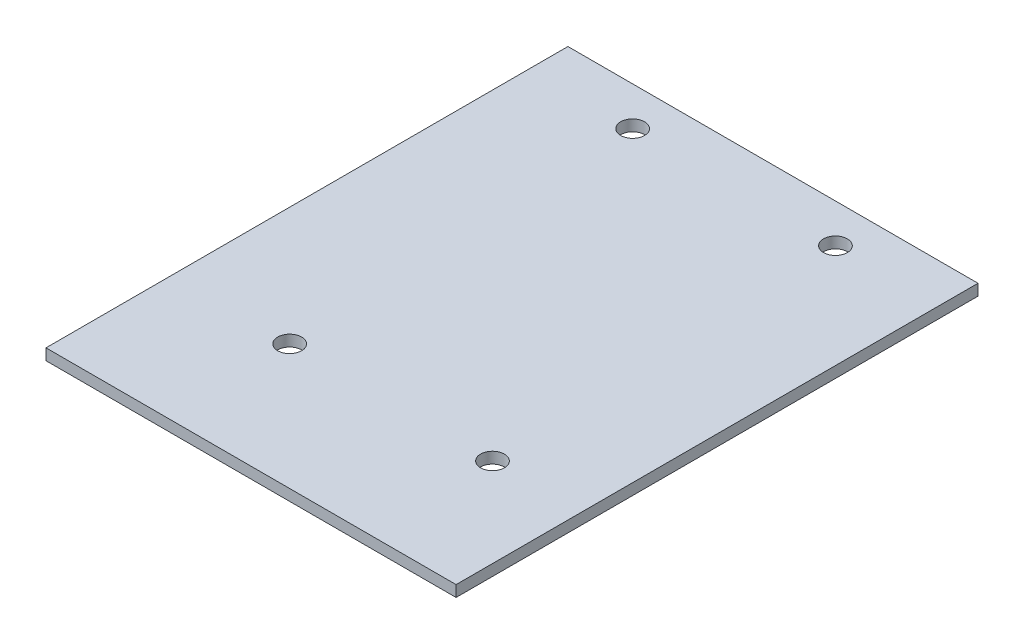
from build123d import *

# Parameters (mm, degrees)
SKIZZE1_W                       = 55
SKIZZE1_H                       = 70
AUFSATZ_LINEAR_AUSTRAGEN1_DEPTH = 1.5
SKIZZE2_R                       = 1.6
SCHNITT_LINEAR_AUSTRAGEN1_DEPTH = 1.5


with BuildPart() as part:
    # Skizze1 → Aufsatz-Linear austragen1 (new body)
    with BuildSketch(Plane(origin=(0, 0, 0), x_dir=(1, 0, 0), z_dir=(0, 1, 0))):
        with Locations((27.5, 35)):
            Rectangle(SKIZZE1_W, SKIZZE1_H)
    extrude(amount=AUFSATZ_LINEAR_AUSTRAGEN1_DEPTH)

    # Skizze2 → Schnitt-Linear austragen1 (cut)
    with BuildSketch(Plane(origin=(0, 1.5, 0), x_dir=(1, 0, 0), z_dir=(0, 1, 0))):
        with Locations((13.880800919, 64.8)):
            Circle(SKIZZE2_R)
        with Locations((41.080800919, 64.8)):
            Circle(SKIZZE2_R)
        with Locations((15.880800919, 16.8)):
            Circle(SKIZZE2_R)
        with Locations((43.080800919, 16.8)):
            Circle(SKIZZE2_R)
    extrude(amount=-SCHNITT_LINEAR_AUSTRAGEN1_DEPTH, mode=Mode.SUBTRACT)


solid = part.part
